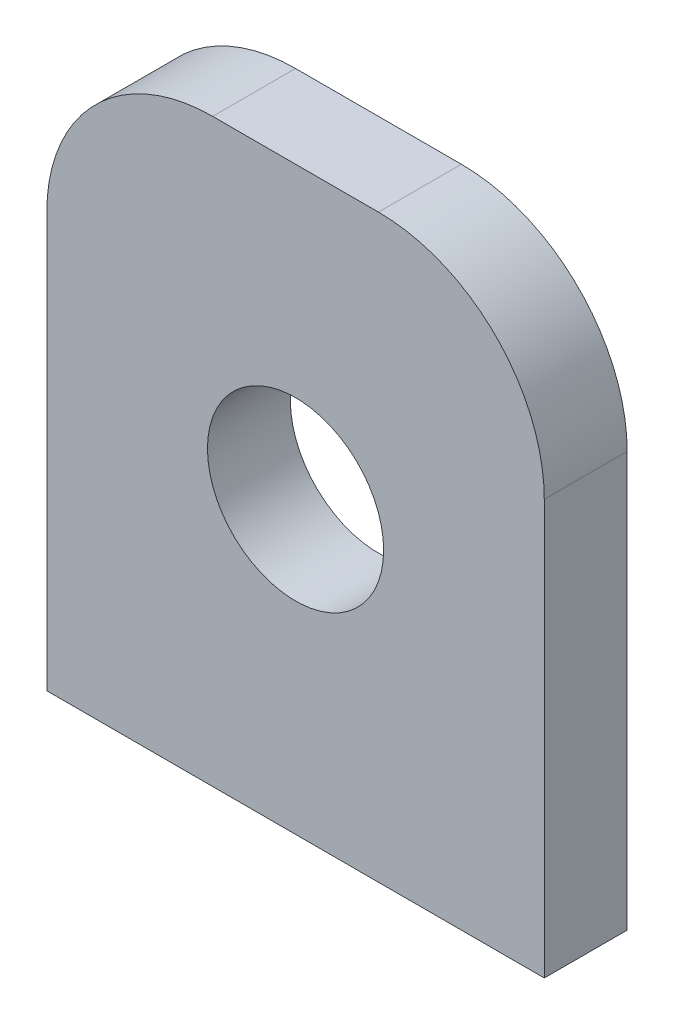
from build123d import *

# Parameters (mm, degrees)
SKETCH1_R                  = 13.49375
BOSS_EXTRUDE1_DEPTH        = 6.35
F_10_32_TAPPED_HOLE1_D     = 4.0386
F_10_32_TAPPED_HOLE1_DEPTH = 12.02944
F_10_32_TAPPED_HOLE1_TIP   = 1.213317848


with BuildPart() as part:
    # Sketch1 → Boss-Extrude1 (new body, symmetric)
    with BuildSketch(Plane.XY):
        with BuildLine():
            Line((38.1, -44.45), (-38.1, -44.45))
            Line((-38.1, -44.45), (-38.1, 19.05))
            ThreePointArc((-38.1, 19.05), (-30.660512242, 37.010512242), (-12.7, 44.45))
            Line((-12.7, 44.45), (12.7, 44.45))
            ThreePointArc((12.7, 44.45), (30.660512242, 37.010512242), (38.1, 19.05))
            Line((38.1, 19.05), (38.1, -44.45))
        make_face()
        Circle(SKETCH1_R, mode=Mode.SUBTRACT)
    extrude(amount=BOSS_EXTRUDE1_DEPTH, both=True)

    # #10-32 Tapped Hole1
    with Locations(Plane(origin=(0, -44.45, 0), x_dir=(-1, 0, 0), z_dir=(0, -1, 0))):
        with Locations((19.05, 0), (-19.05, 0)):
            Hole(F_10_32_TAPPED_HOLE1_D / 2, depth=F_10_32_TAPPED_HOLE1_DEPTH)
            with Locations((0, 0, -(F_10_32_TAPPED_HOLE1_DEPTH + F_10_32_TAPPED_HOLE1_TIP / 2))):  # 118° drill point
                Cone(0, F_10_32_TAPPED_HOLE1_D / 2, F_10_32_TAPPED_HOLE1_TIP, mode=Mode.SUBTRACT)


solid = part.part
